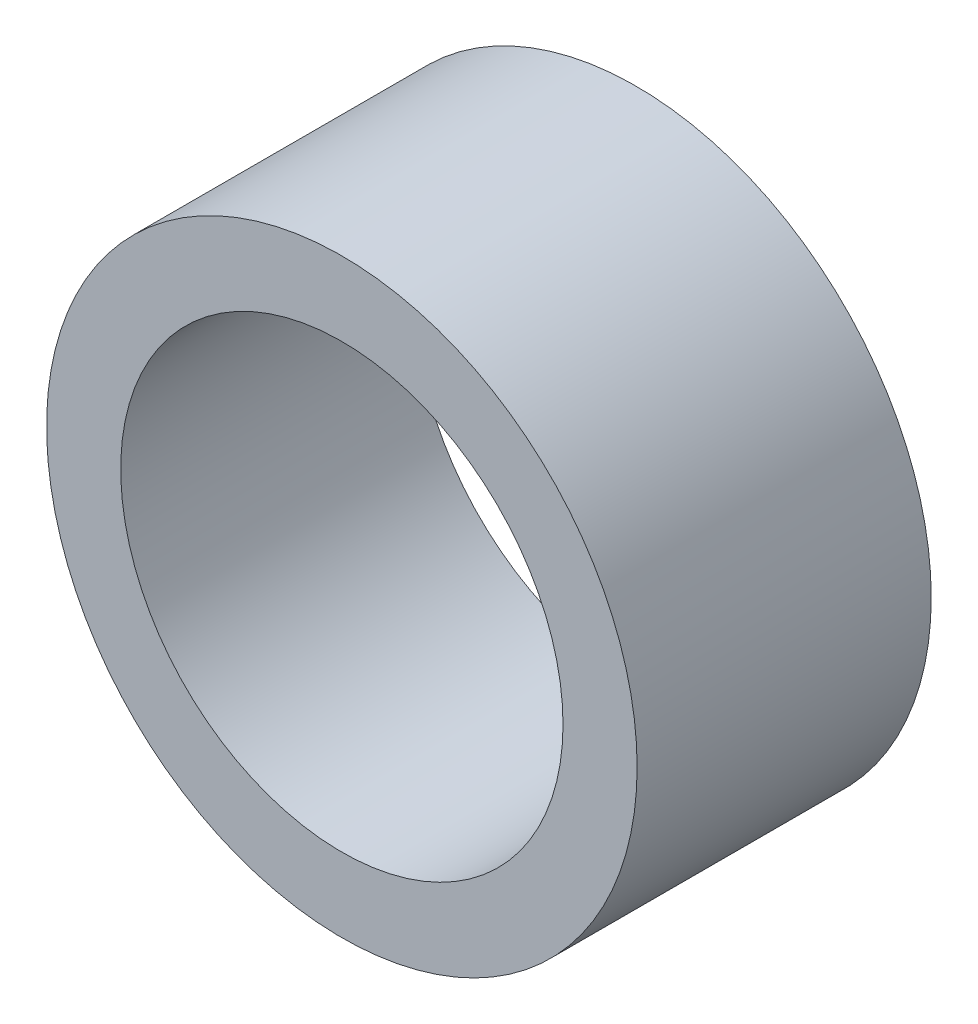
from build123d import *

# Parameters (mm, degrees)
SKETCH1_R           = 6.3754
SKETCH1_R_2         = 4.7752
BOSS_EXTRUDE1_DEPTH = 3.175


with BuildPart() as part:
    # Sketch1 → Boss-Extrude1 (new body, symmetric)
    with BuildSketch(Plane.XY):
        Circle(SKETCH1_R)
        Circle(SKETCH1_R_2, mode=Mode.SUBTRACT)
    extrude(amount=BOSS_EXTRUDE1_DEPTH, both=True)


solid = part.part
